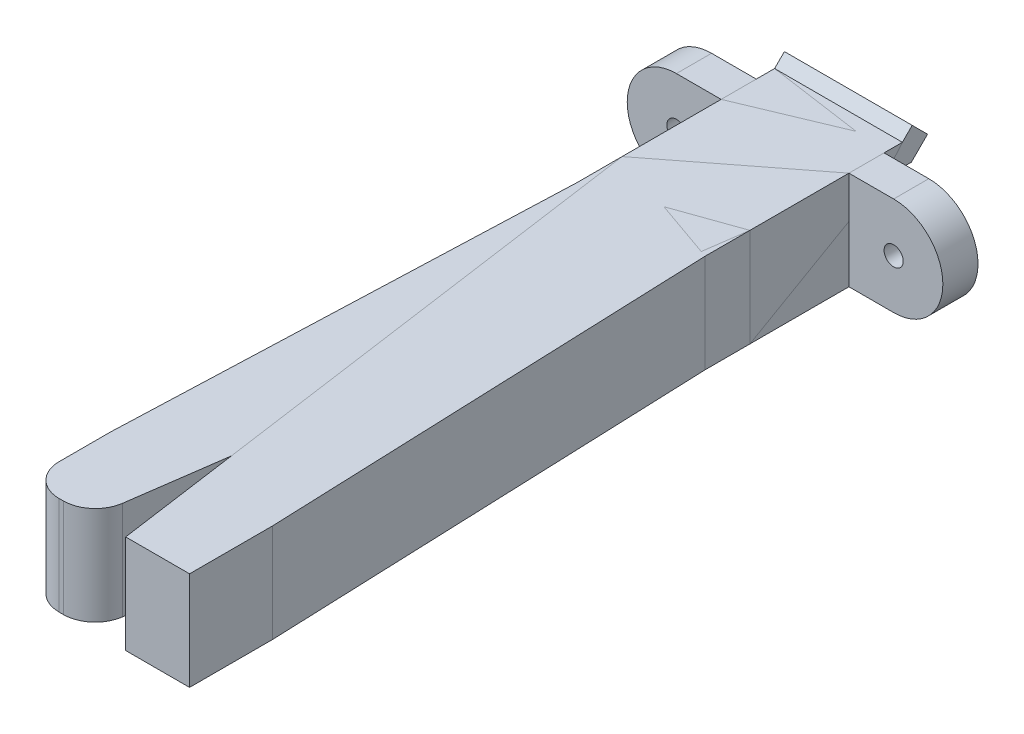
from build123d import *

# Parameters (mm, degrees)
SKETCH2_W           = 10
SKETCH2_H           = 14.768412439
BOSS_EXTRUDE1_DEPTH = 5
BOSS_EXTRUDE4_DEPTH = 10
SKETCH9_W           = 10
SKETCH9_H           = 3.18
SKETCH9_H_2         = 3.888412439
CUT_EXTRUDE3_DEPTH  = 5
BOSS_EXTRUDE5_DEPTH = 7.7
SKETCH12_R          = 0.75
BOSS_EXTRUDE7_DEPTH = 2.75
FILLET1_R           = 2.5


with BuildPart() as part:
    # Sketch2 → Boss-Extrude1 (new body)
    with BuildSketch(Plane.XY):
        with Locations((0, 1.566049366)):
            Rectangle(SKETCH2_W, SKETCH2_H)
    extrude(amount=BOSS_EXTRUDE1_DEPTH)

    # Sketch8 → Boss-Extrude4 (add)
    with BuildSketch(Plane.ZY.offset(5)):
        Polygon((-0.15, 5.770255585), (0, 5.770255585), (0, 4.070255585), (-0.15, 4.070255585), (-2.137867966, 4.070255585), (-3.402081528, 5.334469147), (-2.2, 6.536550675), (-1.43370491, 5.770255585), align=None)
        Polygon((-0.15, -1.929744415), (0, -1.929744415), (0, -0.229744415), (-0.15, -0.229744415), (-1.43370491, -0.229744415), (-2.2, 0.536550675), (-3.402081528, -0.665530853), (-2.137867966, -1.929744415), align=None)
    extrude(amount=-BOSS_EXTRUDE4_DEPTH)

    # Sketch9 → Cut-Extrude3 (cut)
    with BuildSketch(Plane(origin=(0, 0, 0), x_dir=(-1, 0, 0), z_dir=(0, 0, -1))):
        with Locations((0, 7.360255585)):
            Rectangle(SKETCH9_W, SKETCH9_H)
        with Locations((0, -3.873950635)):
            Rectangle(SKETCH9_W, SKETCH9_H_2)
    extrude(amount=-CUT_EXTRUDE3_DEPTH, mode=Mode.SUBTRACT)

    # Sketch10 → Boss-Extrude5 (add)
    with BuildSketch(Plane(origin=(0, 5.770255585, 0), x_dir=(1, 0, 0), z_dir=(0, 1, 0))):
        Polygon((-5, -5), (-5, -10.5), (1.352445729, -55.7), (6.352445729, -55.7), (6.352445729, -49.2), (5, -14), (5, -5), align=None)
    extrude(amount=-BOSS_EXTRUDE5_DEPTH)

    # Sketch12 → Boss-Extrude7 (add)
    with BuildSketch(Plane.XY):
        with BuildLine():
            Line((5, 5.770255585), (8.5, 5.770255585))
            ThreePointArc((8.5, 5.770255585), (12.35, 1.920255585), (8.5, -1.929744415))
            Line((8.5, -1.929744415), (5, -1.929744415))
            Line((5, -1.929744415), (5, 5.770255585))
        make_face()
        with Locations((8.5, 1.920255585)):
            Circle(SKETCH12_R, mode=Mode.SUBTRACT)
    extrude(amount=BOSS_EXTRUDE7_DEPTH)


with BuildPart() as body_2:
    # Mirror1: mirrored copy
    add(part.part.mirror(Plane(origin=(0, 0, 0), x_dir=(0, 0, 1), z_dir=(1, 0, 0))))

    # Fillet1
    fillet1_edges = [body_2.edges().sort_by_distance(p)[0] for p in [
        (-6.352445729, 1.920255585, 49.2),
        (-5, 1.920255585, 14),
        (-1.352445729, 1.920255585, 55.7),
        (-6.352445729, 1.920255585, 55.7),
    ]]
    fillet(fillet1_edges, radius=FILLET1_R)


solid = Compound([part.part, body_2.part])
